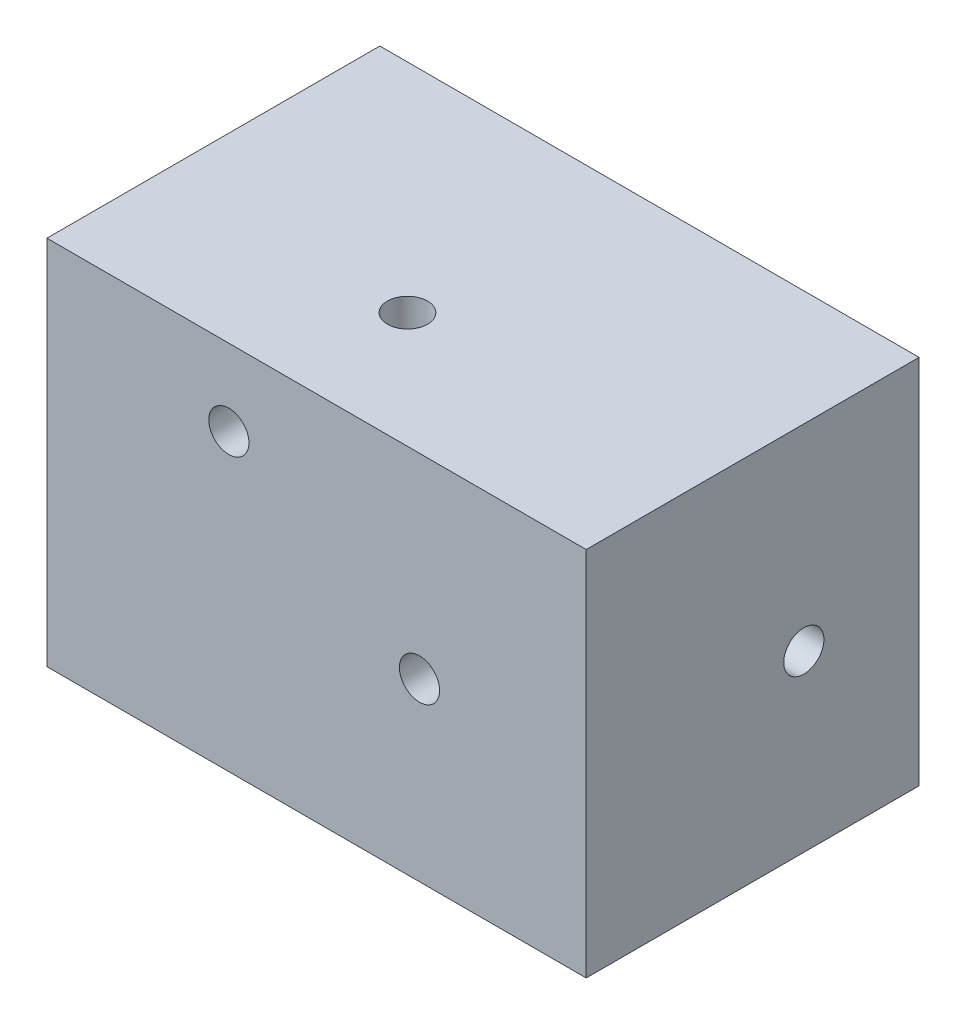
from build123d import *

# Parameters (mm, degrees)
SKETCH1_W      = 136.900969975
SKETCH1_H      = 94.199596476
EXTRUDE1_DEPTH = 84.5


with BuildPart() as part:
    # Sketch1 → Extrude1 (new body)
    with BuildSketch(Plane.XY):
        with Locations((1.93720992, -3.5737201)):
            Rectangle(SKETCH1_W, SKETCH1_H)
    extrude(amount=EXTRUDE1_DEPTH)

    # Sketch2 → M12 Tapped Hole1 (revolve, cut)
    with BuildSketch(Plane(origin=(-4.381234194, 43.526078138, 55.113795081), x_dir=(0, 0, 1), z_dir=(1, 0, 0))):
        Polygon((0, 0), (0, 35.814389157), (0, 46.449423676), (3.383397233, 43.526078138), (3.383397233, 33.781439001), (5.1, 32.75), (5.1, 0), align=None)
    revolve(axis=Axis((-4.381234194, 49.876078138, 55.113795081), (0, -1, 0)), mode=Mode.SUBTRACT)

    # Sketch2 at point 2 (carried to point 2, square into its face) → M12 Tapped Hole1 at 2 (revolve, cut)
    with BuildSketch(Plane(origin=(-20.330054758, 24.148847321, 84.5), x_dir=(0, -1, 0), z_dir=(1, 0, 0))):
        Polygon((0, 0), (0, 35.814389157), (0, 46.449423676), (3.383397233, 43.526078138), (3.383397233, 33.781439001), (5.1, 32.75), (5.1, 0), align=None)
    revolve(axis=Axis((-20.330054758, 24.148847321, 90.85), (0, 0, -1)), mode=Mode.SUBTRACT)

    # Sketch2 at point 3 (carried to point 3, square into its face) → M12 Tapped Hole1 at 3 (revolve, cut)
    with BuildSketch(Plane(origin=(28.063494867, -6.101798408, 84.5), x_dir=(0, -1, 0), z_dir=(1, 0, 0))):
        Polygon((0, 0), (0, 35.814389157), (0, 46.449423676), (3.383397233, 43.526078138), (3.383397233, 33.781439001), (5.1, 32.75), (5.1, 0), align=None)
    revolve(axis=Axis((28.063494867, -6.101798408, 90.85), (0, 0, -1)), mode=Mode.SUBTRACT)

    # Sketch2 at point 4 (carried to point 4, square into its face) → M12 Tapped Hole1 at 4 (revolve, cut)
    with BuildSketch(Plane(origin=(70.387694908, -6.390360142, 29.257323255), x_dir=(0, 0, 1), z_dir=(0, -1, 0))):
        Polygon((0, 0), (0, 35.814389157), (0, 46.449423676), (3.383397233, 43.526078138), (3.383397233, 33.781439001), (5.1, 32.75), (5.1, 0), align=None)
    revolve(axis=Axis((76.737694908, -6.390360142, 29.257323255), (-1, 0, 0)), mode=Mode.SUBTRACT)

    # Sketch2 at point 5 (carried to point 5, square into its face) → M12 Tapped Hole1 at 5 (revolve, cut)
    with BuildSketch(Plane(origin=(37.293087605, -19.39205915, 0), x_dir=(0, 1, 0), z_dir=(1, 0, 0))):
        Polygon((0, 0), (0, 35.814389157), (0, 46.449423676), (3.383397233, 43.526078138), (3.383397233, 33.781439001), (5.1, 32.75), (5.1, 0), align=None)
    revolve(axis=Axis((37.293087605, -19.39205915, -6.35), (0, 0, 1)), mode=Mode.SUBTRACT)


solid = part.part
